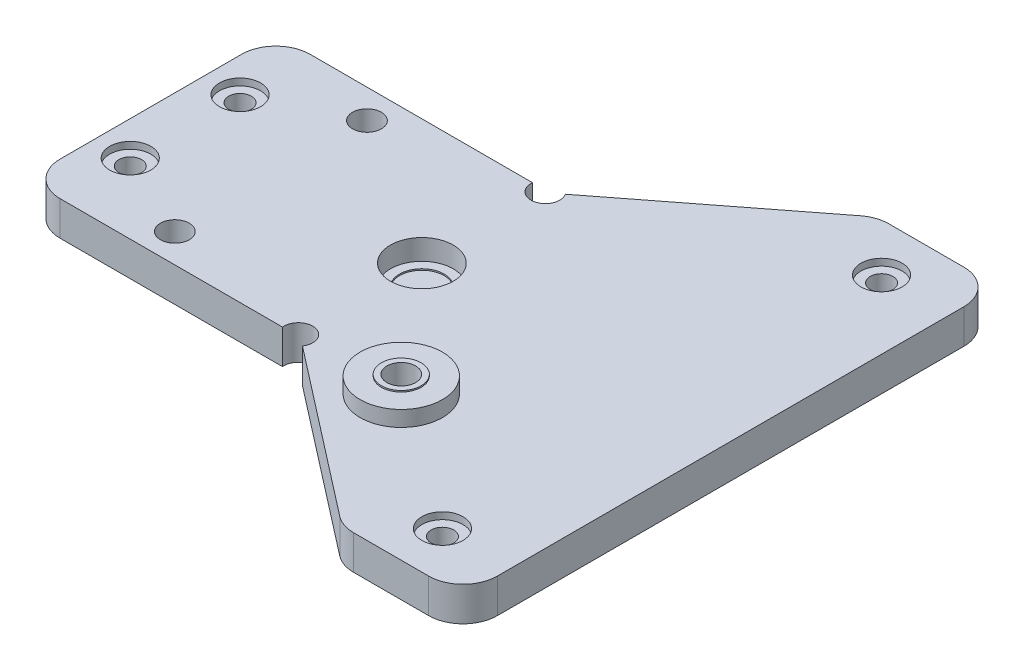
from build123d import *

# Parameters (mm, degrees)
SKETCH1_W           = 115
SKETCH1_H           = 60
SKETCH1_R           = 2.1
BOSS_EXTRUDE1_DEPTH = 5
SKETCH2_R           = 4.575
CUT_EXTRUDE1_DEPTH  = 3
SKETCH3_R           = 3.25
CUT_EXTRUDE2_DEPTH  = 0.2
SKETCH4_R           = 1.65
CUT_EXTRUDE3_DEPTH  = 6
CUT_EXTRUDE4_DEPTH  = 6
BOSS_EXTRUDE2_DEPTH = 5
SKETCH8_R           = 1.65
CUT_EXTRUDE5_DEPTH  = 6
FILLET1_R           = 5
SKETCH9_R           = 6
SKETCH9_R_2         = 2.1
BOSS_EXTRUDE3_DEPTH = 2.275
SKETCH10_R          = 2.9
SKETCH10_R_2        = 2.1
BOSS_EXTRUDE4_DEPTH = 0.2
SKETCH11_R          = 3
CUT_EXTRUDE6_DEPTH  = 1


with BuildPart() as part:
    # Sketch1 → Boss-Extrude1 (new body)
    with BuildSketch(Plane(origin=(0, 0, 0), x_dir=(1, 0, 0), z_dir=(0, 1, 0))):
        with Locations((-12.5, 0)):
            Rectangle(SKETCH1_W, SKETCH1_H)
        with Locations((-22, 14)):
            Circle(SKETCH1_R, mode=Mode.SUBTRACT)
        with Locations((0, 18)):
            Circle(SKETCH1_R, mode=Mode.SUBTRACT)
        with Locations((0, -18)):
            Circle(SKETCH1_R, mode=Mode.SUBTRACT)
        with Locations((-22, -14)):
            Circle(SKETCH1_R, mode=Mode.SUBTRACT)
        with Locations((15, -18)):
            Circle(SKETCH1_R, mode=Mode.SUBTRACT)
    extrude(amount=BOSS_EXTRUDE1_DEPTH)

    # Sketch2 → Cut-Extrude1 (cut)
    with BuildSketch(Plane(origin=(0, 5, 0), x_dir=(1, 0, 0), z_dir=(0, 1, 0))):
        Circle(SKETCH2_R)
    extrude(amount=-CUT_EXTRUDE1_DEPTH, mode=Mode.SUBTRACT)

    # Sketch3 → Cut-Extrude2 (cut)
    with BuildSketch(Plane(origin=(0, 2, 0), x_dir=(1, 0, 0), z_dir=(0, 1, 0))):
        Circle(SKETCH3_R)
    extrude(amount=-CUT_EXTRUDE2_DEPTH, mode=Mode.SUBTRACT)

    # Sketch4 → Cut-Extrude3 (cut, through all)
    with BuildSketch(Plane(origin=(0, 5, 0), x_dir=(1, 0, 0), z_dir=(0, 1, 0))):
        with Locations((-34.5, -8)):
            Circle(SKETCH4_R)
        with Locations((-34.5, 8)):
            Circle(SKETCH4_R)
    extrude(amount=-CUT_EXTRUDE3_DEPTH, mode=Mode.SUBTRACT)

    # Sketch6 → Cut-Extrude4 (cut, through all)
    with BuildSketch(Plane(origin=(0, 5, 0), x_dir=(1, 0, 0), z_dir=(0, 1, 0))):
        with BuildLine():
            Line((-22, 18.221576202), (-34.5, 18.221576202))
            ThreePointArc((-34.5, 18.221576202), (-38.035533906, 16.757110108), (-39.5, 13.221576202))
            Line((-39.5, 13.221576202), (-39.5, -13.221576202))
            ThreePointArc((-39.5, -13.221576202), (-38.035533906, -16.757110108), (-34.5, -18.221576202))
            Line((-34.5, -18.221576202), (-22, -18.221576202))
            Line((-22, -18.221576202), (-8.297519941, -18.221576202))
            Line((-8.297519941, -18.221576202), (0.548980681, -18.221576202))
            Line((0.548980681, -18.221576202), (26.801199277, -38.580439602))
            Line((26.801199277, -38.580439602), (-22, -30))
            Line((-22, -30), (-70, -30))
            Line((-70, -30), (-70, 30))
            Line((-70, 30), (-22, 30))
            Line((-22, 30), (26.801199277, 38.580439602))
            Line((26.801199277, 38.580439602), (0.548980681, 18.221576202))
            Line((0.548980681, 18.221576202), (-8.297519941, 18.221576202))
            Line((-8.297519941, 18.221576202), (-22, 18.221576202))
        make_face()
    extrude(amount=-CUT_EXTRUDE4_DEPTH, mode=Mode.SUBTRACT)

    # Sketch7 → Boss-Extrude2 (add)
    with BuildSketch(Plane(origin=(0, 5, 0), x_dir=(1, 0, 0), z_dir=(0, 1, 0))):
        Polygon((27.342211368, 39), (15.73694821, 30), (45, 30), (45, 39), align=None)
        Polygon((45, -30), (15.73694821, -30), (27.342211368, -39), (45, -39), align=None)
    extrude(amount=-BOSS_EXTRUDE2_DEPTH)

    # Sketch8 → Cut-Extrude5 (cut, through all)
    with BuildSketch(Plane(origin=(0, 5, 0), x_dir=(1, 0, 0), z_dir=(0, 1, 0))):
        with Locations((35, 32)):
            Circle(SKETCH8_R)
        with Locations((35, -32)):
            Circle(SKETCH8_R)
    extrude(amount=-CUT_EXTRUDE5_DEPTH, mode=Mode.SUBTRACT)

    # Fillet1
    fillet1_edges = [part.edges().sort_by_distance(p)[0] for p in [
        (45, 2.5, -39),
        (27.342211368, 2.5, -39),
        (27.342211368, 2.5, 39),
        (45, 2.5, 39),
    ]]
    fillet(fillet1_edges, radius=FILLET1_R)

    # Sketch9 → Boss-Extrude3 (add)
    with BuildSketch(Plane(origin=(0, 5, 0), x_dir=(1, 0, 0), z_dir=(0, 1, 0))):
        with Locations((15, -18)):
            Circle(SKETCH9_R)
        with Locations((15, -18)):
            Circle(SKETCH9_R_2, mode=Mode.SUBTRACT)
    extrude(amount=BOSS_EXTRUDE3_DEPTH)

    # Sketch10 → Boss-Extrude4 (add)
    with BuildSketch(Plane(origin=(0, 7.275, 0), x_dir=(1, 0, 0), z_dir=(0, 1, 0))):
        with Locations((15, -18)):
            Circle(SKETCH10_R)
        with Locations((15, -18)):
            Circle(SKETCH10_R_2, mode=Mode.SUBTRACT)
    extrude(amount=BOSS_EXTRUDE4_DEPTH)

    # Sketch11 → Cut-Extrude6 (cut)
    with BuildSketch(Plane(origin=(0, 5, 0), x_dir=(1, 0, 0), z_dir=(0, 1, 0))):
        with Locations((-34.5, 8)):
            Circle(SKETCH11_R)
        with Locations((-34.5, -8)):
            Circle(SKETCH11_R)
        with Locations((35, -32)):
            Circle(SKETCH11_R)
        with Locations((35, 32)):
            Circle(SKETCH11_R)
    extrude(amount=-CUT_EXTRUDE6_DEPTH, mode=Mode.SUBTRACT)


solid = part.part
